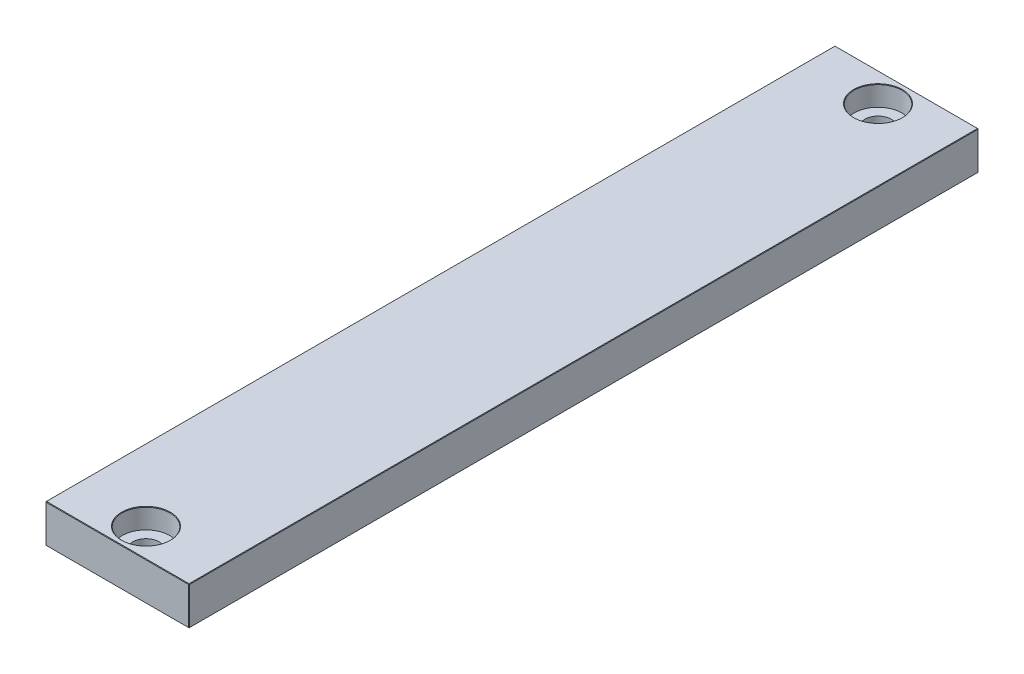
from build123d import *

# Parameters (mm, degrees)
SKETCH1_W           = 30
SKETCH1_H           = 165
SKETCH1_R           = 2.75
BOSS_EXTRUDE2_DEPTH = 8
SKETCH3_R           = 5
CUT_EXTRUDE1_DEPTH  = 4.2
CHAMFER1_SIZE       = 0.1


with BuildPart() as part:
    # Sketch1 → Boss-Extrude2 (new body)
    with BuildSketch(Plane(origin=(0, 0, 0), x_dir=(1, 0, 0), z_dir=(0, 1, 0))):
        Rectangle(SKETCH1_W, SKETCH1_H)
        with Locations((0, 76.5)):
            Circle(SKETCH1_R, mode=Mode.SUBTRACT)
        with Locations((0, -76.5)):
            Circle(SKETCH1_R, mode=Mode.SUBTRACT)
    extrude(amount=BOSS_EXTRUDE2_DEPTH)

    # Sketch3 → Cut-Extrude1 (cut)
    with BuildSketch(Plane(origin=(0, 8, 0), x_dir=(1, 0, 0), z_dir=(0, 1, 0))):
        with Locations((0, 76.5)):
            Circle(SKETCH3_R)
        with Locations((0, -76.5)):
            Circle(SKETCH3_R)
    extrude(amount=-CUT_EXTRUDE1_DEPTH, mode=Mode.SUBTRACT)

    # Chamfer1
    chamfer1_edges = [part.edges().sort_by_distance(p)[0] for p in [
        (-2.75, 0, -76.5),
        (-15, 8, 0),
        (-2.75, 0, 76.5),
        (0, 8, 82.5),
        (-5, 8, -76.5),
        (-5, 8, 76.5),
        (15, 8, 0),
        (0, 0, 82.5),
        (-15, 0, 0),
        (0, 0, -82.5),
        (15, 0, 0),
        (15, 4, 82.5),
        (-15, 4, 82.5),
        (-15, 4, -82.5),
        (15, 4, -82.5),
        (0, 8, -82.5),
    ]]
    chamfer(chamfer1_edges, length=CHAMFER1_SIZE)


solid = part.part
